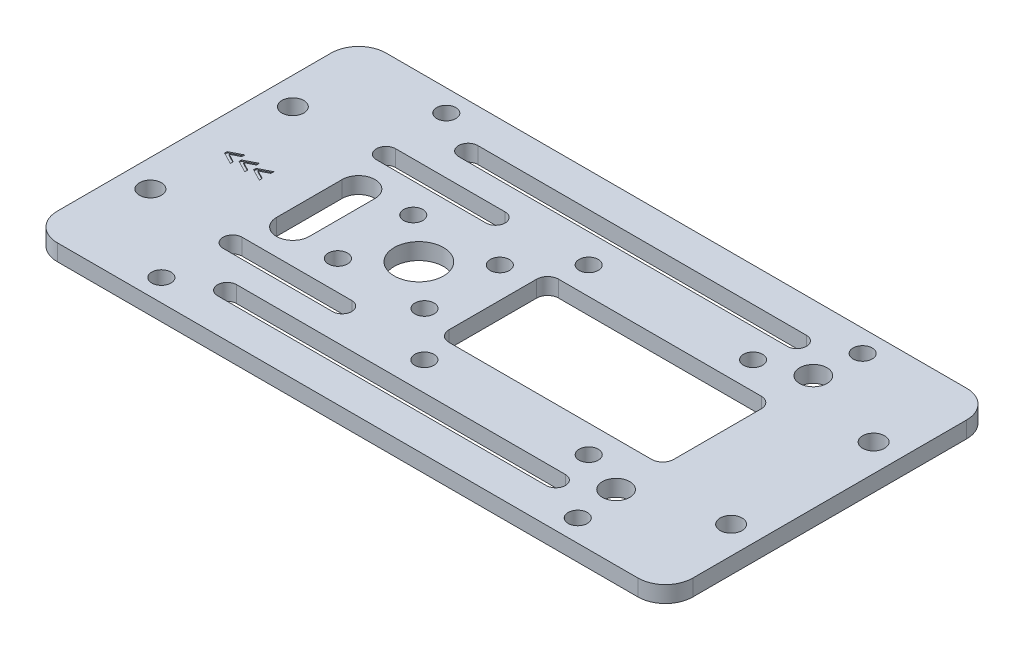
from build123d import *

# Parameters (mm, degrees)
SKETCH1_W              = 116
SKETCH1_H              = 60
SKETCH1_R              = 2
BOSS_EXTRUDE1_DEPTH    = 3
SKETCH2_R              = 1.75
ODROID_HOLES_DEPTH     = 66.368187982
CUT_EXTRUDE2_DEPTH     = 0.2
SKETCH4_R              = 1.75
PIXHAWK_PM_DEPTH       = 66.368187982
SKETCH5_R              = 1.75
BUCKCONVERTER_5A_DEPTH = 66.368187982
SKETCH6_R              = 2.5
SKETCH6_R_2            = 4.5
CUT_EXTRUDE5_DEPTH     = 66.368187982
FILLET1_R              = 5


with BuildPart() as part:
    # Sketch1 → Boss-Extrude1 (new body)
    with BuildSketch(Plane(origin=(0, 0, 0), x_dir=(1, 0, 0), z_dir=(0, 1, 0))):
        Rectangle(SKETCH1_W, SKETCH1_H)
        with Locations((53, 13)):
            Circle(SKETCH1_R, mode=Mode.SUBTRACT)
        with Locations((53, -13)):
            Circle(SKETCH1_R, mode=Mode.SUBTRACT)
        with Locations((-53, -13)):
            Circle(SKETCH1_R, mode=Mode.SUBTRACT)
        with Locations((-53, 13)):
            Circle(SKETCH1_R, mode=Mode.SUBTRACT)
    extrude(amount=BOSS_EXTRUDE1_DEPTH)

    # Sketch2 → Odroid-holes (cut, through all)
    with BuildSketch(Plane(origin=(0, 3, 0), x_dir=(1, 0, 0), z_dir=(0, 1, 0))):
        with Locations((38, 26)):
            Circle(SKETCH2_R)
        with Locations((38, -26)):
            Circle(SKETCH2_R)
        with Locations((-38, -26)):
            Circle(SKETCH2_R)
        with Locations((-38, 26)):
            Circle(SKETCH2_R)
    extrude(amount=-ODROID_HOLES_DEPTH, mode=Mode.SUBTRACT)

    # Sketch3 → Cut-Extrude2 (cut)
    with BuildSketch(Plane(origin=(0, 3, 0), x_dir=(1, 0, 0), z_dir=(0, 1, 0))):
        Polygon((-49.756039442, -1.122419343), (-49.756039442, -1.666214416), (-51.913411237, -0.552547549), (-51.913411237, -0.104155121), (-49.756039442, 1.009511746), (-49.756039442, 0.465080657), (-51.293930067, -0.328669343), align=None)
        Polygon((-47.110206109, -1.122419343), (-47.110206109, -1.666214416), (-49.267577904, -0.552547549), (-49.267577904, -0.104155121), (-47.110206109, 1.009511746), (-47.110206109, 0.465080657), (-48.648096734, -0.328669343), align=None)
        Polygon((-44.464372776, -1.122419343), (-44.464372776, -1.666214416), (-46.621744571, -0.552547549), (-46.621744571, -0.104155121), (-44.464372776, 1.009511746), (-44.464372776, 0.465080657), (-46.002263401, -0.328669343), align=None)
    extrude(amount=-CUT_EXTRUDE2_DEPTH, mode=Mode.SUBTRACT)

    # Sketch4 → Pixhawk-PM (cut, through all)
    with BuildSketch(Plane(origin=(0, 3, 0), x_dir=(1, 0, 0), z_dir=(0, 1, 0))):
        with Locations((-1, 15)):
            Circle(SKETCH4_R)
        with Locations((29, 15)):
            Circle(SKETCH4_R)
        with Locations((29, -15)):
            Circle(SKETCH4_R)
        with Locations((-1, -15)):
            Circle(SKETCH4_R)
    extrude(amount=-PIXHAWK_PM_DEPTH, mode=Mode.SUBTRACT)

    # Sketch5 → BuckConverter-5A (cut, through all)
    with BuildSketch(Plane(origin=(0, 3, 0), x_dir=(1, 0, 0), z_dir=(0, 1, 0))):
        with Locations((-9.1, 6.875)):
            Circle(SKETCH5_R)
        with Locations((-24.9, 6.875)):
            Circle(SKETCH5_R)
        with Locations((-24.9, -6.875)):
            Circle(SKETCH5_R)
        with Locations((-9.1, -6.875)):
            Circle(SKETCH5_R)
    extrude(amount=-BUCKCONVERTER_5A_DEPTH, mode=Mode.SUBTRACT)

    # Sketch6 → Cut-Extrude5 (cut, through all)
    with BuildSketch(Plane(origin=(0, 3, 0), x_dir=(1, 0, 0), z_dir=(0, 1, 0))):
        with BuildLine():
            Line((30, 23.75), (-30, 23.75))
            ThreePointArc((-30, 23.75), (-31.75, 22), (-30, 20.25))
            Line((-30, 20.25), (30, 20.25))
            ThreePointArc((30, 20.25), (31.75, 22), (30, 23.75))
        make_face()
        with BuildLine():
            ThreePointArc((-30, -20.25), (-31.75, -22), (-30, -23.75))
            Line((-30, -23.75), (30, -23.75))
            ThreePointArc((30, -23.75), (31.75, -22), (30, -20.25))
            Line((30, -20.25), (-30, -20.25))
        make_face()
        with BuildLine():
            Line((-17, 15.75), (-37, 15.75))
            ThreePointArc((-37, 15.75), (-38.75, 14), (-37, 12.25))
            Line((-37, 12.25), (-17, 12.25))
            ThreePointArc((-17, 12.25), (-15.25, 14), (-17, 15.75))
        make_face()
        with BuildLine():
            ThreePointArc((-37, -12.25), (-38.75, -14), (-37, -15.75))
            Line((-37, -15.75), (-17, -15.75))
            ThreePointArc((-17, -15.75), (-15.25, -14), (-17, -12.25))
            Line((-17, -12.25), (-37, -12.25))
        make_face()
        with BuildLine():
            Line((35.5, 10), (-1.5, 10))
            ThreePointArc((-1.5, 10), (-2.914213562, 9.414213562), (-3.5, 8))
            Line((-3.5, 8), (-3.5, -8))
            ThreePointArc((-3.5, -8), (-2.914213562, -9.414213562), (-1.5, -10))
            Line((-1.5, -10), (35.5, -10))
            ThreePointArc((35.5, -10), (36.914213562, -9.414213562), (37.5, -8))
            Line((37.5, -8), (37.5, 8))
            ThreePointArc((37.5, 8), (36.914213562, 9.414213562), (35.5, 10))
        make_face()
        with BuildLine():
            Line((-31, -6), (-31, 6))
            ThreePointArc((-31, 6), (-34, 9), (-37, 6))
            Line((-37, 6), (-37, -6))
            ThreePointArc((-37, -6), (-34, -9), (-31, -6))
        make_face()
        with Locations((37, 18)):
            Circle(SKETCH6_R)
        with Locations((37, -18)):
            Circle(SKETCH6_R)
        with Locations((-17, 0)):
            Circle(SKETCH6_R_2)
    extrude(amount=-CUT_EXTRUDE5_DEPTH, mode=Mode.SUBTRACT)

    # Fillet1
    fillet1_edges = [part.edges().sort_by_distance(p)[0] for p in [
        (58, 1.5, -30),
        (58, 1.5, 30),
        (-58, 1.5, 30),
        (-58, 1.5, -30),
    ]]
    fillet(fillet1_edges, radius=FILLET1_R)


solid = part.part
